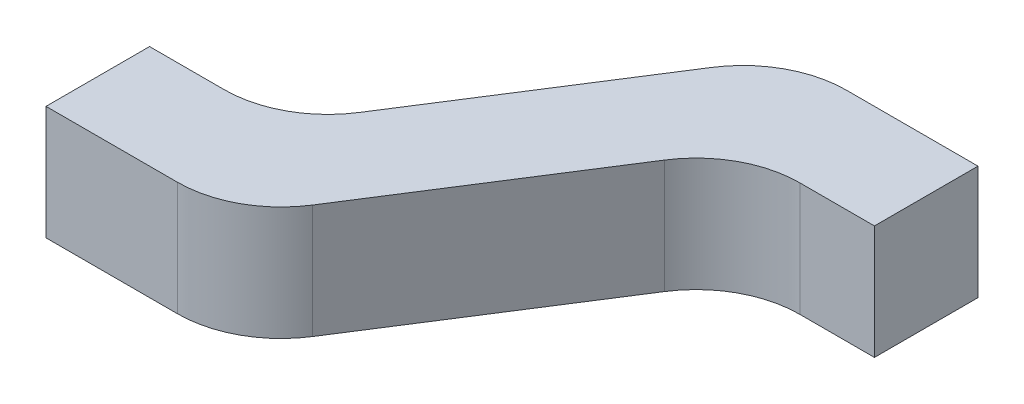
from build123d import *

# Parameters (mm, degrees)
BOSS_EXTRUDE1_DEPTH = 0.11


with BuildPart() as part:
    # Sketch1 → Boss-Extrude1 (new body, symmetric)
    with BuildSketch(Plane(origin=(0, 0, 0), x_dir=(1, 0, 0), z_dir=(0, 1, 0))):
        with BuildLine():
            Line((0, -0.1), (0.253926549, -0.1))
            ThreePointArc((0.253926549, -0.1), (0.350102065, -0.07535755), (0.422577577, -0.007502702))
            Line((0.422577577, -0.007502702), (0.687113185, 0.407502702))
            ThreePointArc((0.687113185, 0.407502702), (0.759588697, 0.47535755), (0.855764212, 0.5))
            Line((0.855764212, 0.5), (1, 0.5))
            Line((1, 0.5), (1, 0.7))
            Line((1, 0.7), (0.746073451, 0.7))
            ThreePointArc((0.746073451, 0.7), (0.649897935, 0.67535755), (0.577422423, 0.607502702))
            Line((0.577422423, 0.607502702), (0.312886815, 0.192497298))
            ThreePointArc((0.312886815, 0.192497298), (0.240411303, 0.12464245), (0.144235788, 0.1))
            Line((0.144235788, 0.1), (0, 0.1))
            Line((0, 0.1), (0, -0.1))
        make_face()
    extrude(amount=BOSS_EXTRUDE1_DEPTH, both=True)


solid = part.part
